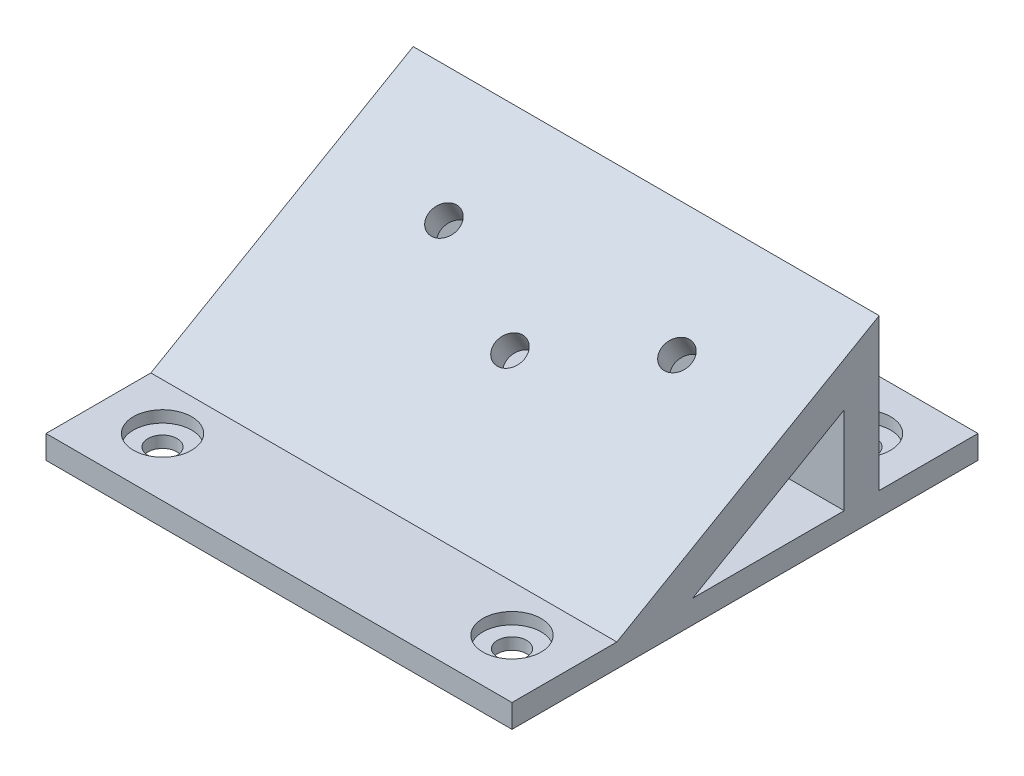
from build123d import *

# Parameters (mm, degrees)
SKETCH1_W           = 40
SKETCH1_H           = 40
BOSS_EXTRUDE1_DEPTH = 2
SKETCH2_R           = 1.25
CUT_EXTRUDE1_DEPTH  = 3
BOSS_EXTRUDE2_DEPTH = 40
SKETCH5_R           = 2.5
CUT_EXTRUDE3_DEPTH  = 1
CUT_EXTRUDE4_DEPTH  = 41
CUT_EXTRUDE5_REACH  = 19.232
SKETCH6_R           = 1.25
SKETCH11_R          = 2.6
CUT_EXTRUDE6_DEPTH  = 1.2


with BuildPart() as part:
    # Sketch1 → Boss-Extrude1 (new body)
    with BuildSketch(Plane(origin=(0, 0, 0), x_dir=(1, 0, 0), z_dir=(0, 1, 0))):
        with Locations((-12.069207341, -7.637914169)):
            Rectangle(SKETCH1_W, SKETCH1_H)
    extrude(amount=BOSS_EXTRUDE1_DEPTH)

    # Sketch2 → Cut-Extrude1 (cut, through all)
    with BuildSketch(Plane(origin=(0, 2, 0), x_dir=(1, 0, 0), z_dir=(0, 1, 0))):
        with Locations((-27.069207341, -22.637914169)):
            Circle(SKETCH2_R)
        with Locations((-27.069207341, 7.362085831)):
            Circle(SKETCH2_R)
        with Locations((2.930792659, 7.362085831)):
            Circle(SKETCH2_R)
        with Locations((2.930792659, -22.637914169)):
            Circle(SKETCH2_R)
    extrude(amount=-CUT_EXTRUDE1_DEPTH, mode=Mode.SUBTRACT)

    # Sketch4 → Boss-Extrude2 (add)
    with BuildSketch(Plane(origin=(7.930792659, 0, 0), x_dir=(0, 0, -1), z_dir=(1, 0, 0))):
        Polygon((-18.637914169, 2), (3.878746329, 2), (3.878746329, 15), align=None)
    extrude(amount=-BOSS_EXTRUDE2_DEPTH)

    # Sketch5 → Cut-Extrude3 (cut)
    with BuildSketch(Plane(origin=(0, 2, 0), x_dir=(1, 0, 0), z_dir=(0, 1, 0))):
        with Locations((2.930792659, 7.362085831)):
            Circle(SKETCH5_R)
        with Locations((2.930792659, -22.637914169)):
            Circle(SKETCH5_R)
        with Locations((37.902040206, 5.850032714)):
            Circle(SKETCH5_R)
        with Locations((-27.069207341, 7.362085831)):
            Circle(SKETCH5_R)
        with Locations((-27.069207341, -22.637914169)):
            Circle(SKETCH5_R)
    extrude(amount=-CUT_EXTRUDE3_DEPTH, mode=Mode.SUBTRACT)

    # Sketch9 → Cut-Extrude4 (cut, through all)
    with BuildSketch(Plane(origin=(7.930792659, 0, 0), x_dir=(0, 0, -1), z_dir=(1, 0, 0))):
        Polygon((-12.121253671, 2), (0.878746329, 2), (0.878746329, 9.505553499), align=None)
    extrude(amount=-CUT_EXTRUDE4_DEPTH, mode=Mode.SUBTRACT)

    # Sketch6 → Cut-Extrude5 (cut, up to next)
    with BuildSketch(Plane(origin=(0, 9.570453572, 5.525503946), x_dir=(1, 0, 0), z_dir=(0, 0.866025404, 0.5)), mode=Mode.PRIVATE) as cut_extrude5_sk1:
        with Locations((-22.069207341, 2.359092856)):
            Circle(SKETCH6_R)
    cut_extrude5_tool1 = extrude(cut_extrude5_sk1.sketch, amount=-CUT_EXTRUDE5_REACH, mode=Mode.PRIVATE) & part.part
    add(cut_extrude5_tool1.solids().sort_by_distance((-22.069207, 10.75, 3.48247))[0], mode=Mode.SUBTRACT)
    # Sketch6 → Cut-Extrude5 (cut, up to next)
    with BuildSketch(Plane(origin=(0, 9.570453572, 5.525503946), x_dir=(1, 0, 0), z_dir=(0, 0.866025404, 0.5)), mode=Mode.PRIVATE) as cut_extrude5_sk2:
        with Locations((-12.069207341, -2.640907144)):
            Circle(SKETCH6_R)
    cut_extrude5_tool2 = extrude(cut_extrude5_sk2.sketch, amount=-CUT_EXTRUDE5_REACH, mode=Mode.PRIVATE) & part.part
    add(cut_extrude5_tool2.solids().sort_by_distance((-12.069207, 8.25, 7.812597))[0], mode=Mode.SUBTRACT)
    # Sketch6 → Cut-Extrude5 (cut, up to next)
    with BuildSketch(Plane(origin=(0, 9.570453572, 5.525503946), x_dir=(1, 0, 0), z_dir=(0, 0.866025404, 0.5)), mode=Mode.PRIVATE) as cut_extrude5_sk3:
        with Locations((-2.069207341, 2.359092856)):
            Circle(SKETCH6_R)
    cut_extrude5_tool3 = extrude(cut_extrude5_sk3.sketch, amount=-CUT_EXTRUDE5_REACH, mode=Mode.PRIVATE) & part.part
    add(cut_extrude5_tool3.solids().sort_by_distance((-2.069207, 10.75, 3.48247))[0], mode=Mode.SUBTRACT)

    # Sketch11 → Cut-Extrude6 (cut)
    with BuildSketch(Plane(origin=(0, 6.748656802, 3.896338821), x_dir=(-1, 0, 0), z_dir=(0, -0.866025404, -0.5))):
        with Locations((2.069207341, 2.359092856)):
            Circle(SKETCH11_R)
        with Locations((22.069207341, 2.359092856)):
            Circle(SKETCH11_R)
        with Locations((12.069207341, -2.640907144)):
            Circle(SKETCH11_R)
    extrude(amount=-CUT_EXTRUDE6_DEPTH, mode=Mode.SUBTRACT)


solid = part.part
